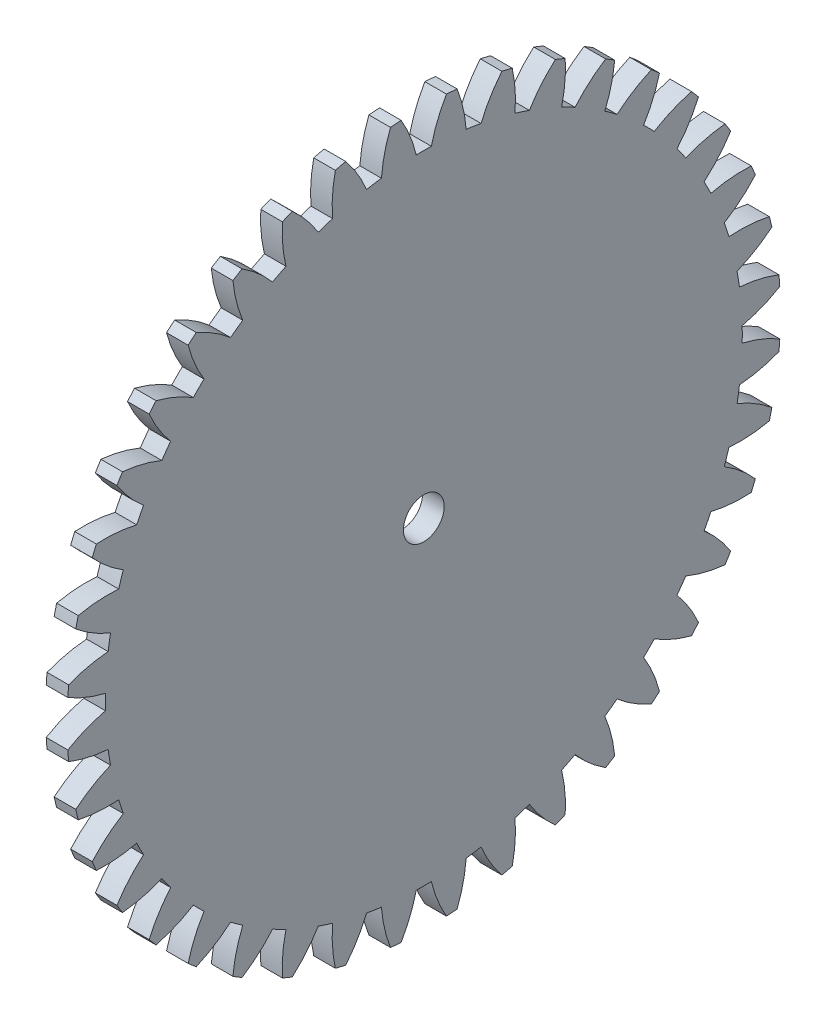
from build123d import *

# Parameters (mm, degrees)
BASPROSKE_W     = 3.18
BASPROSKE_H     = 52.5
TOOTHCUT_DEPTH  = 75.314281265
TEETHCUTS_COUNT = 40
TEETHCUTS_ANGLE = 351
BORSKE_R        = 3
BORE_DEPTH      = 50.0000508


with BuildPart() as part:
    # BasProSke → Base-Revolve (revolve)
    with BuildSketch(Plane(origin=(0, 0, 0), x_dir=(1, 0, 0), z_dir=(0, 1, 0)), mode=Mode.PRIVATE) as base_revolve_sk:
        with Locations((1.59, 26.25)):
            Rectangle(BASPROSKE_W, BASPROSKE_H)
    revolve(base_revolve_sk.sketch.rotate(Axis((-10, 0, 0), (1, 0, 0)), 180), axis=Axis((-10, 0, 0), (1, 0, 0)))

    # TooCutSke → ToothCut (cut, through all)
    with BuildSketch(Plane(origin=(0, 0, 0), x_dir=(0, 0, -1), z_dir=(1, 0, 0))):
        with BuildLine():
            ThreePointArc((1.108908031, 46.86088133), (0, 46.874), (-1.108908031, 46.86088133))
            ThreePointArc((-1.108908031, 46.86088133), (-2.020311534, 49.724086633), (-3.350376445, 52.418437814))
            ThreePointArc((-3.350376445, 52.418437814), (0, 52.5254), (3.350376445, 52.418437814))
            ThreePointArc((3.350376445, 52.418437814), (2.020311534, 49.724086633), (1.108908031, 46.86088133))
        make_face()
    toothcut = extrude(amount=TOOTHCUT_DEPTH, mode=Mode.SUBTRACT)

    # TeethCuts: ToothCut ×40 about axis
    teethcuts_axis = Axis((-10, 0, 0), (1, 0, 0))
    for i in range(1, TEETHCUTS_COUNT):
        add(toothcut.rotate(teethcuts_axis, i * TEETHCUTS_ANGLE / (TEETHCUTS_COUNT - 1)), mode=Mode.SUBTRACT)

    # BorSke → Bore (cut, symmetric)
    with BuildSketch(Plane(origin=(0, 0, 0), x_dir=(0, 0, -1), z_dir=(1, 0, 0))):
        with Locations(Location((0, 0, 0), (0, 0, 180))):
            Circle(BORSKE_R)
    extrude(amount=BORE_DEPTH, both=True, mode=Mode.SUBTRACT)


solid = part.part
